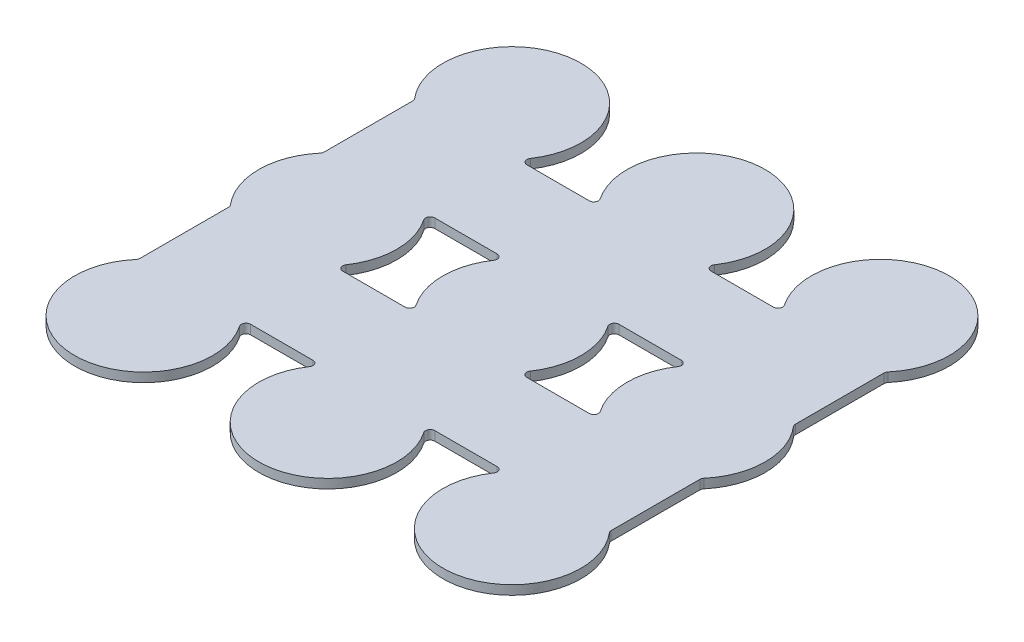
from build123d import *
from build123d.topology import SkipClean

# Parameters (mm, degrees)
L_U_BR_IST_W               = 55
L_U_BR_IST_H               = 55
AUFSATZ_LIN_GK_DEPTH       = 1
SCHNITT_LIN_S1_DEPTH       = 2
SCHNITT_LIN_S2_DEPTH       = 2
SCHNITT_LIN_S3_DEPTH       = 2
SCHNITT_LIN_S4_DEPTH       = 2
LIN_MUSTER_S1_COUNT        = 2
LIN_MUSTER_S1_PITCH        = 20
LIN_MUSTER_S1_COUNT_DIR2   = 3
LIN_MUSTER_S1_PITCH_DIR2   = 20
LIN_MUSTER_S2_COUNT        = 2
LIN_MUSTER_S2_PITCH        = 20
LIN_MUSTER_S3_COUNT        = 2
LIN_MUSTER_S3_PITCH        = 20
SPIEGELN_S4_Z_COPY_1_DEPTH = 2
SPIEGELN_S2_COPY_1_DEPTH   = 2
SPIEGELN_S3_COPY_1_DEPTH   = 2
SPIEGELN_S3_COPY_2_DEPTH   = 2


with BuildPart() as part:
    # L_ u Br Ist → Aufsatz-Lin_GK (new body)
    with BuildSketch(Plane(origin=(0, 0, 0), x_dir=(1, 0, 0), z_dir=(0, 1, 0))):
        with Locations((10.772595927, -7.907273432)):
            Rectangle(L_U_BR_IST_W, L_U_BR_IST_H)
    extrude(amount=-AUFSATZ_LIN_GK_DEPTH)

    # Sketch S1 → Schnitt-Lin_S1 (cut, through all)
    with BuildSketch(Plane(origin=(0, 0, 0), x_dir=(1, 0, 0), z_dir=(0, 1, 0))):
        with BuildLine():
            Line((-2.613025796, 7.092726568), (4.158217649, 7.092726568))
            ThreePointArc((4.158217649, 7.092726568), (4.600159387, 7.358872981), (4.571616291, 7.873976568))
            ThreePointArc((4.571616291, 7.873976568), (3.272595927, 12.092726568), (4.571616291, 16.311476568))
            ThreePointArc((4.571616291, 16.311476568), (4.600159387, 16.826580155), (4.158217649, 17.092726568))
            Line((4.158217649, 17.092726568), (-2.613025796, 17.092726568))
            ThreePointArc((-2.613025796, 17.092726568), (-3.054967534, 16.826580155), (-3.026424438, 16.311476568))
            ThreePointArc((-3.026424438, 16.311476568), (-1.727404073, 12.092726568), (-3.026424438, 7.873976568))
            ThreePointArc((-3.026424438, 7.873976568), (-3.054967534, 7.358872981), (-2.613025796, 7.092726568))
        make_face()
    schnitt_lin_s1 = extrude(amount=-SCHNITT_LIN_S1_DEPTH, mode=Mode.SUBTRACT)

    # Sketch S2 → Schnitt-Lin_S2 (cut, through all)
    with BuildSketch(Plane(origin=(0, 0, 0), x_dir=(1, 0, 0), z_dir=(0, 1, 0))):
        with BuildLine():
            Line((-14.817574017, -2.719804872), (-14.817574017, 6.905258008))
            ThreePointArc((-14.817574017, 6.905258008), (-14.848363078, 7.07800376), (-14.936938396, 7.229474793))
            ThreePointArc((-14.936938396, 7.229474793), (-16.26556816, 9.501540297), (-16.727404073, 12.092726568))
            Line((-16.727404073, 12.092726568), (-16.727404073, -7.907273432))
            ThreePointArc((-16.727404073, -7.907273432), (-16.26556816, -5.316087161), (-14.936938396, -3.044021657))
            ThreePointArc((-14.936938396, -3.044021657), (-14.848363078, -2.892550624), (-14.817574017, -2.719804872))
        make_face()
    schnitt_lin_s2 = extrude(amount=-SCHNITT_LIN_S2_DEPTH, mode=Mode.SUBTRACT)

    # Sketch S3 → Schnitt-Lin_S3 (cut, through all)
    with BuildSketch(Plane(origin=(0, 0, 0), x_dir=(1, 0, 0), z_dir=(0, 1, 0))):
        with BuildLine():
            Line((-3.026424438, 16.311476568), (4.571616291, 16.311476568))
            ThreePointArc((4.571616291, 16.311476568), (7.264792127, 18.721852642), (10.772595927, 19.592726568))
            Line((10.772595927, 19.592726568), (-9.227404073, 19.592726568))
            ThreePointArc((-9.227404073, 19.592726568), (-5.719600273, 18.721852642), (-3.026424438, 16.311476568))
        make_face()
    schnitt_lin_s3 = extrude(amount=-SCHNITT_LIN_S3_DEPTH, mode=Mode.SUBTRACT)

    # Sketch S4 → Schnitt-Lin_S4 (cut, through all)
    with SkipClean():  # keep this step's faces unmerged: merging them makes the solid invalid here
        with BuildSketch(Plane(origin=(0, 0, 0), x_dir=(1, 0, 0), z_dir=(0, 1, 0))):
            with BuildLine():
                Line((-16.727404073, 12.092726568), (-16.727404073, 19.592726568))
                Line((-16.727404073, 19.592726568), (-9.227404073, 19.592726568))
                ThreePointArc((-9.227404073, 19.592726568), (-14.530704932, 17.396027427), (-16.727404073, 12.092726568))
            make_face()
        schnitt_lin_s4 = extrude(amount=-SCHNITT_LIN_S4_DEPTH, mode=Mode.SUBTRACT)

    # Lin Muster_S1: Schnitt-Lin_S1 2 × 3
    with SkipClean():  # keep this step's faces unmerged: merging them makes the solid invalid here
        with Locations(*[(i * LIN_MUSTER_S1_PITCH, 0, j * LIN_MUSTER_S1_PITCH_DIR2) for i in range(LIN_MUSTER_S1_COUNT) for j in range(LIN_MUSTER_S1_COUNT_DIR2) if (i, j) != (0, 0)]):
            add(schnitt_lin_s1, mode=Mode.SUBTRACT)

    # Lin Muster_S2: Schnitt-Lin_S2 ×2
    with SkipClean():  # keep this step's faces unmerged: merging them makes the solid invalid here
        with Locations(*[(0, 0, i * LIN_MUSTER_S2_PITCH) for i in range(1, LIN_MUSTER_S2_COUNT)]):
            add(schnitt_lin_s2, mode=Mode.SUBTRACT)

    # Lin Muster_S3: Schnitt-Lin_S3 ×2
    with SkipClean():  # keep this step's faces unmerged: merging them makes the solid invalid here
        with Locations(*[(i * LIN_MUSTER_S3_PITCH, 0, 0) for i in range(1, LIN_MUSTER_S3_COUNT)]):
            add(schnitt_lin_s3, mode=Mode.SUBTRACT)

    # Spiegeln_S4 X: Schnitt-Lin_S4 across plane
    with SkipClean():  # keep this step's faces unmerged: merging them makes the solid invalid here
        add(schnitt_lin_s4.mirror(Plane.ZY.offset(-10.772595927)), mode=Mode.SUBTRACT)

    # Spiegeln_S4 Z: Schnitt-Lin_S4 across plane
    with SkipClean():  # keep this step's faces unmerged: merging them makes the solid invalid here
        add(schnitt_lin_s4.mirror(Plane.XY.offset(7.907273432)), mode=Mode.SUBTRACT)

    # Spiegeln_S4 Z copy 1 sketch → Spiegeln_S4 Z copy 1 (cut, through all)
    with SkipClean():  # keep this step's faces unmerged: merging them makes the solid invalid here
        with BuildSketch(Plane(origin=(21.545191853, 0, 15.814546864), x_dir=(-1, 0, 0), z_dir=(0, 1, 0))):
            with BuildLine():
                Line((-16.727404073, 12.092726568), (-16.727404073, 19.592726568))
                Line((-16.727404073, 19.592726568), (-9.227404073, 19.592726568))
                ThreePointArc((-9.227404073, 19.592726568), (-14.530704932, 17.396027427), (-16.727404073, 12.092726568))
            make_face()
        extrude(amount=-SPIEGELN_S4_Z_COPY_1_DEPTH, mode=Mode.SUBTRACT)

    # Spiegeln_S2: Schnitt-Lin_S2 across plane
    with SkipClean():  # keep this step's faces unmerged: merging them makes the solid invalid here
        add(schnitt_lin_s2.mirror(Plane.ZY.offset(-10.772595927)), mode=Mode.SUBTRACT)

    # Spiegeln_S2 copy 1 sketch → Spiegeln_S2 copy 1 (cut, through all)
    with SkipClean():  # keep this step's faces unmerged: merging them makes the solid invalid here
        with BuildSketch(Plane(origin=(21.545191853, 0, 20), x_dir=(-1, 0, 0), z_dir=(0, 1, 0))):
            with BuildLine():
                Line((-14.817574017, 2.719804872), (-14.817574017, -6.905258008))
                ThreePointArc((-14.817574017, -6.905258008), (-14.848363078, -7.07800376), (-14.936938396, -7.229474793))
                ThreePointArc((-14.936938396, -7.229474793), (-16.26556816, -9.501540297), (-16.727404073, -12.092726568))
                Line((-16.727404073, -12.092726568), (-16.727404073, 7.907273432))
                ThreePointArc((-16.727404073, 7.907273432), (-16.26556816, 5.316087161), (-14.936938396, 3.044021657))
                ThreePointArc((-14.936938396, 3.044021657), (-14.848363078, 2.892550624), (-14.817574017, 2.719804872))
            make_face()
        extrude(amount=-SPIEGELN_S2_COPY_1_DEPTH, mode=Mode.SUBTRACT)

    # Spiegeln_S3 copy 1 sketch → Spiegeln_S3 copy 1 (cut, through all)
    with SkipClean():  # keep this step's faces unmerged: merging them makes the solid invalid here
        with BuildSketch(Plane(origin=(20, 0, 15.814546864), x_dir=(1, 0, 0), z_dir=(0, 1, 0))):
            with BuildLine():
                Line((-3.026424438, -16.311476568), (4.571616291, -16.311476568))
                ThreePointArc((4.571616291, -16.311476568), (7.264792127, -18.721852642), (10.772595927, -19.592726568))
                Line((10.772595927, -19.592726568), (-9.227404073, -19.592726568))
                ThreePointArc((-9.227404073, -19.592726568), (-5.719600273, -18.721852642), (-3.026424438, -16.311476568))
            make_face()
        extrude(amount=-SPIEGELN_S3_COPY_1_DEPTH, mode=Mode.SUBTRACT)

    # Spiegeln_S3 copy 2 sketch → Spiegeln_S3 copy 2 (cut, through all)
    with SkipClean():  # keep this step's faces unmerged: merging them makes the solid invalid here
        with BuildSketch(Plane(origin=(0, 0, 15.814546864), x_dir=(1, 0, 0), z_dir=(0, 1, 0))):
            with BuildLine():
                Line((-3.026424438, -16.311476568), (4.571616291, -16.311476568))
                ThreePointArc((4.571616291, -16.311476568), (7.264792127, -18.721852642), (10.772595927, -19.592726568))
                Line((10.772595927, -19.592726568), (-9.227404073, -19.592726568))
                ThreePointArc((-9.227404073, -19.592726568), (-5.719600273, -18.721852642), (-3.026424438, -16.311476568))
            make_face()
        extrude(amount=-SPIEGELN_S3_COPY_2_DEPTH, mode=Mode.SUBTRACT)


solid = part.part
